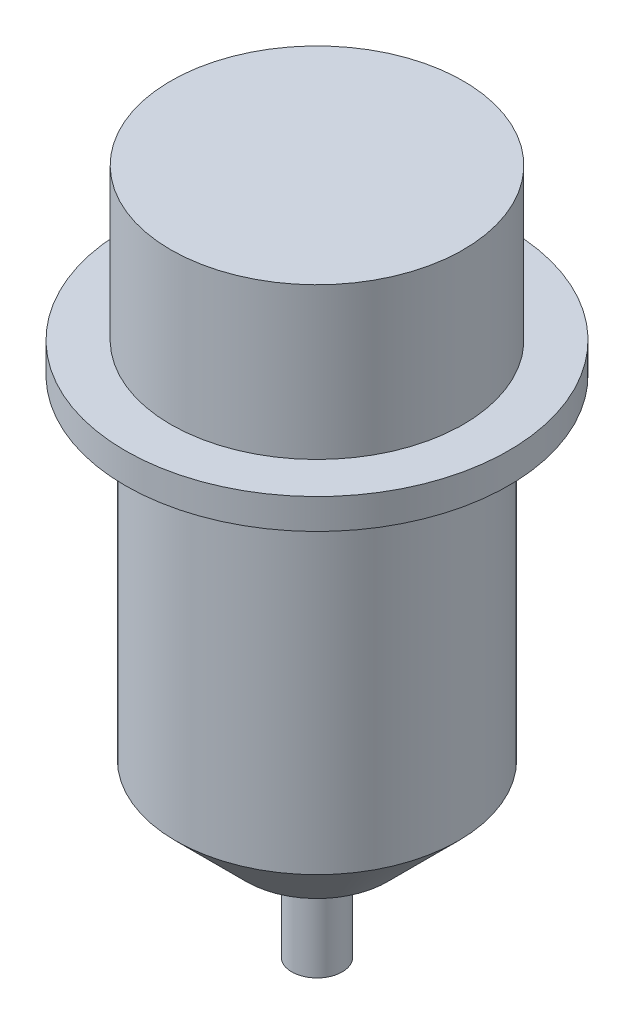
from build123d import *

# Parameters (mm, degrees)
SKETCH_1_R      = 14
EXTRUDE_1_DEPTH = 40
CHAMFER_1_SIZE  = 7
SKETCH_2_R      = 19
EXTRUDE_2_DEPTH = 3
SKETCH_3_R      = 14.5
EXTRUDE_3_DEPTH = 15
SKETCH_4_R      = 2.5
EXTRUDE_4_DEPTH = 10


with BuildPart() as part:
    # Эскиз1 → Бобышка-Вытянуть1 (new body)
    with BuildSketch(Plane(origin=(0, 0, 0), x_dir=(1, 0, 0), z_dir=(0, 1, 0))):
        Circle(SKETCH_1_R)
    extrude(amount=-EXTRUDE_1_DEPTH)

    # Фаска1
    chamfer_1_edges = [part.edges().sort_by_distance(p)[0] for p in [
        (-14, -40, 0),
    ]]
    chamfer(chamfer_1_edges, length=CHAMFER_1_SIZE)

    # Эскиз2 → Бобышка-Вытянуть2 (add)
    with BuildSketch(Plane(origin=(0, 0, 0), x_dir=(1, 0, 0), z_dir=(0, 1, 0))):
        Circle(SKETCH_2_R)
    extrude(amount=EXTRUDE_2_DEPTH)

    # Эскиз3 → Бобышка-Вытянуть3 (add)
    with BuildSketch(Plane(origin=(0, 3, 0), x_dir=(1, 0, 0), z_dir=(0, 1, 0))):
        Circle(SKETCH_3_R)
    extrude(amount=EXTRUDE_3_DEPTH)

    # Эскиз4 → Бобышка-Вытянуть4 (add)
    with BuildSketch(Plane.XZ.offset(40)):
        Circle(SKETCH_4_R)
    extrude(amount=EXTRUDE_4_DEPTH)


solid = part.part
